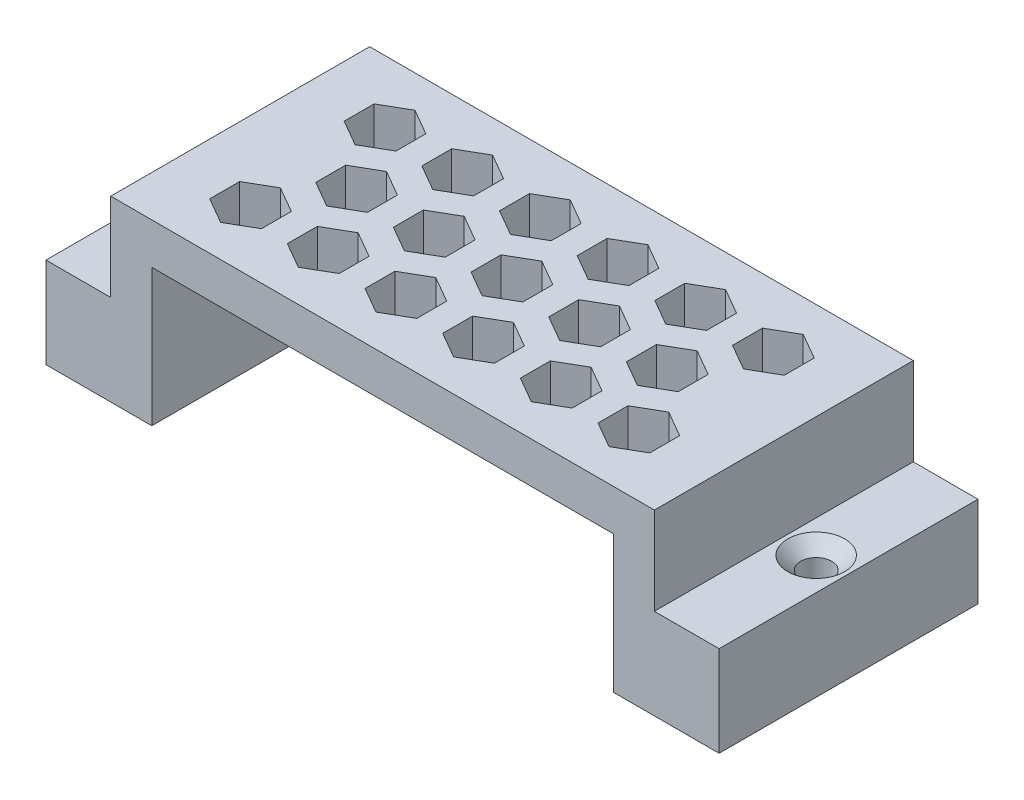
from build123d import *

# Parameters (mm, degrees)
SKETCH1_W                                       = 42
SKETCH1_H                                       = 20
BOSS_EXTRUDE1_DEPTH                             = 13.775
SHELL1_T                                        = -3.175
SKETCH2_W                                       = 20
SKETCH2_H                                       = 7
BOSS_EXTRUDE2_DEPTH                             = 5
CUT_EXTRUDE1_DEPTH                              = 3.175
CSK_FOR_M2_FLAT_HEAD_MACHINE_SCREW1_D           = 2.4
CSK_FOR_M2_FLAT_HEAD_MACHINE_SCREW1_CSINK_D     = 4.4
CSK_FOR_M2_FLAT_HEAD_MACHINE_SCREW1_CSINK_ANGLE = 90


with BuildPart() as part:
    # Sketch1 → Boss-Extrude1 (new body)
    with BuildSketch(Plane(origin=(0, 0, 0), x_dir=(1, 0, 0), z_dir=(0, 1, 0))):
        Rectangle(SKETCH1_W, SKETCH1_H)
    extrude(amount=BOSS_EXTRUDE1_DEPTH)

    # Shell1
    shell1_openings = [part.faces().sort_by_distance(p)[0] for p in [
        (0, 0, 0),
        (0, 6.8875, 10),
    ]]
    offset(amount=SHELL1_T, openings=shell1_openings, kind=Kind.INTERSECTION)

    # Sketch2 → Boss-Extrude2 (add)
    with BuildSketch(Plane(origin=(21, 0, 0), x_dir=(0, 0, -1), z_dir=(1, 0, 0))):
        with Locations((0, 3.5)):
            Rectangle(SKETCH2_W, SKETCH2_H)
    boss_extrude2 = extrude(amount=BOSS_EXTRUDE2_DEPTH)

    # Mirror1: Boss-Extrude2 across plane
    add(boss_extrude2.mirror(Plane(origin=(0, 0, 0), x_dir=(0, 0, 1), z_dir=(1, 0, 0))))

    # Sketch3 → Cut-Extrude1 (cut)
    with BuildSketch(Plane(origin=(0, 13.775, 0), x_dir=(1, 0, 0), z_dir=(0, 1, 0))):
        Polygon((-4, -1.160254038), (-4, 1.149147039), (-6, 2.303847577), (-8, 1.149147039), (-8, -1.160254038), (-6, -2.314954576), align=None)
        Polygon((-10, -1.160254038), (-10, 1.149147039), (-12, 2.303847577), (-14, 1.149147039), (-14, -1.160254038), (-12, -2.314954576), align=None)
        Polygon((-13, 4.035898385), (-13, 6.345299462), (-15, 7.5), (-17, 6.345299462), (-17, 4.035898385), (-15, 2.881197846), align=None)
        Polygon((-7, 4.035898385), (-7, 6.345299462), (-9, 7.5), (-11, 6.345299462), (-11, 4.035898385), (-9, 2.881197846), align=None)
        Polygon((2, -1.160254038), (2, 1.149147039), (0, 2.303847577), (-2, 1.149147039), (-2, -1.160254038), (0, -2.314954576), align=None)
        Polygon((-1, 4.035898385), (-1, 6.345299462), (-3, 7.5), (-5, 6.345299462), (-5, 4.035898385), (-3, 2.881197846), align=None)
        Polygon((8, -1.160254038), (8, 1.149147039), (6, 2.303847577), (4, 1.149147039), (4, -1.160254038), (6, -2.314954576), align=None)
        Polygon((5, 4.035898385), (5, 6.345299462), (3, 7.5), (1, 6.345299462), (1, 4.035898385), (3, 2.881197846), align=None)
        Polygon((14, -1.160254038), (14, 1.149147039), (12, 2.303847577), (10, 1.149147039), (10, -1.160254038), (12, -2.314954576), align=None)
        Polygon((11, 4.035898385), (11, 6.345299462), (9, 7.5), (7, 6.345299462), (7, 4.035898385), (9, 2.881197846), align=None)
        Polygon((17, 4.035898385), (17, 6.345299462), (15, 7.5), (13, 6.345299462), (13, 4.035898385), (15, 2.881197846), align=None)
        Polygon((-7, -6.354101615), (-7, -4.044700538), (-9, -2.89), (-11, -4.044700538), (-11, -6.354101615), (-9, -7.508802154), align=None)
        Polygon((-1, -6.354101615), (-1, -4.044700538), (-3, -2.89), (-5, -4.044700538), (-5, -6.354101615), (-3, -7.508802154), align=None)
        Polygon((5, -6.354101615), (5, -4.044700538), (3, -2.89), (1, -4.044700538), (1, -6.354101615), (3, -7.508802154), align=None)
        Polygon((11, -6.354101615), (11, -4.044700538), (9, -2.89), (7, -4.044700538), (7, -6.354101615), (9, -7.508802154), align=None)
        Polygon((17, -6.354101615), (17, -4.044700538), (15, -2.89), (13, -4.044700538), (13, -6.354101615), (15, -7.508802154), align=None)
        Polygon((-13, -6.354101615), (-13, -4.044700538), (-15, -2.89), (-17, -4.044700538), (-17, -6.354101615), (-15, -7.508802154), align=None)
    extrude(amount=-CUT_EXTRUDE1_DEPTH, mode=Mode.SUBTRACT)

    # CSK for M2 Flat Head Machine Screw1 (through all)
    with Locations(Plane(origin=(0, 7, 0), x_dir=(1, 0, 0), z_dir=(0, 1, 0))):
        with Locations((-23.5, 0), (23.5, 0)):
            CounterSinkHole(CSK_FOR_M2_FLAT_HEAD_MACHINE_SCREW1_D / 2, CSK_FOR_M2_FLAT_HEAD_MACHINE_SCREW1_CSINK_D / 2, counter_sink_angle=CSK_FOR_M2_FLAT_HEAD_MACHINE_SCREW1_CSINK_ANGLE)


solid = part.part
